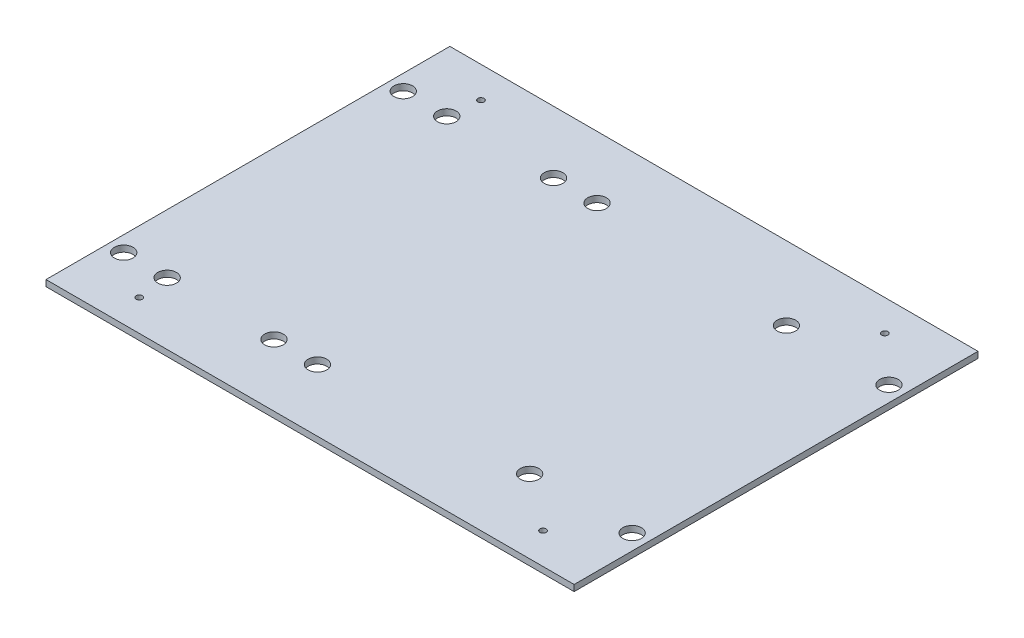
from build123d import *

# Parameters (mm, degrees)
SKETCH1_W           = 170
SKETCH1_H           = 130
SKETCH1_R           = 3
BOSS_EXTRUDE1_DEPTH = 2
SKETCH2_R           = 1
CUT_EXTRUDE1_DEPTH  = 10


with BuildPart() as part:
    # Sketch1 → Boss-Extrude1 (new body)
    with BuildSketch(Plane(origin=(0, 0, 0), x_dir=(1, 0, 0), z_dir=(0, 1, 0))):
        Rectangle(SKETCH1_W, SKETCH1_H)
        with Locations((-80, 45)):
            Circle(SKETCH1_R, mode=Mode.SUBTRACT)
        with Locations((-66, 45)):
            Circle(SKETCH1_R, mode=Mode.SUBTRACT)
        with Locations((-66, -45)):
            Circle(SKETCH1_R, mode=Mode.SUBTRACT)
        with Locations((-80, -45)):
            Circle(SKETCH1_R, mode=Mode.SUBTRACT)
        with Locations((-31.62143128, -45)):
            Circle(SKETCH1_R, mode=Mode.SUBTRACT)
        with Locations((-17.62143128, -45)):
            Circle(SKETCH1_R, mode=Mode.SUBTRACT)
        with Locations((-17.62143128, 45)):
            Circle(SKETCH1_R, mode=Mode.SUBTRACT)
        with Locations((-31.62143128, 45)):
            Circle(SKETCH1_R, mode=Mode.SUBTRACT)
        with Locations((80, 41.33)):
            Circle(SKETCH1_R, mode=Mode.SUBTRACT)
        with Locations((47, 41.33)):
            Circle(SKETCH1_R, mode=Mode.SUBTRACT)
        with Locations((80, -41.33)):
            Circle(SKETCH1_R, mode=Mode.SUBTRACT)
        with Locations((47, -41.33)):
            Circle(SKETCH1_R, mode=Mode.SUBTRACT)
    extrude(amount=BOSS_EXTRUDE1_DEPTH)

    # Sketch2 → Cut-Extrude1 (cut)
    with BuildSketch(Plane(origin=(0, 2, 0), x_dir=(1, 0, 0), z_dir=(0, 1, 0))):
        with Locations((-65, -55)):
            Circle(SKETCH2_R)
        with Locations((-65, 55)):
            Circle(SKETCH2_R)
        with Locations((65, 55)):
            Circle(SKETCH2_R)
        with Locations((65, -55)):
            Circle(SKETCH2_R)
    extrude(amount=-CUT_EXTRUDE1_DEPTH, mode=Mode.SUBTRACT)


solid = part.part
